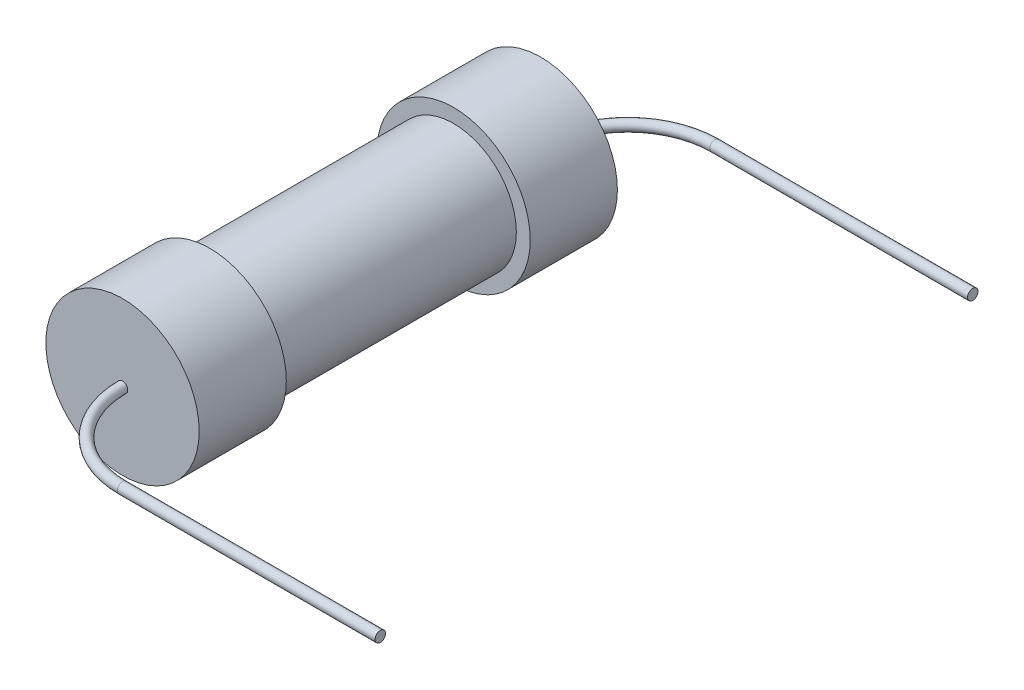
from build123d import *

# Parameters (mm, degrees)
SWEEP_1_PROFILE_R = 0.075


with BuildPart() as part:
    # 草图1 → 旋转1 (revolve)
    with BuildSketch(Plane(origin=(0, 0, 0), x_dir=(1, 0, 0), z_dir=(0, 1, 0))):
        Polygon((0.9, -1.75), (1.1, -1.75), (1.1, -3), (0, -3), (0, 3), (1.1, 3), (1.1, 1.75), (0.9, 1.75), align=None)
    revolve(axis=Axis((0, 0, 3), (0, 0, -1)))

    # 扫描1: sweep along a path in 草图6
    with BuildLine(Plane(origin=(0, 0, 0), x_dir=(1, 0, 0), z_dir=(0, 1, 0))) as sweep_1_path:
        Line((4.948876204, 4.25), (1.25, 4.25))
        ThreePointArc((1.25, 4.25), (0.366116524, 3.883883476), (0, 3))
    # 扫描1 profile (on start of the path) → 扫描1 (sweep)
    with BuildSketch(Plane(origin=(4.948876204, 0, -4.25), x_dir=(0, 0, -1), z_dir=(-1, 0, 0))):
        Circle(SWEEP_1_PROFILE_R)
    sweep_1 = sweep(path=sweep_1_path.line)

    # 镜向1: 扫描1 across plane
    add(sweep_1.mirror(Plane.XY))


solid = part.part
